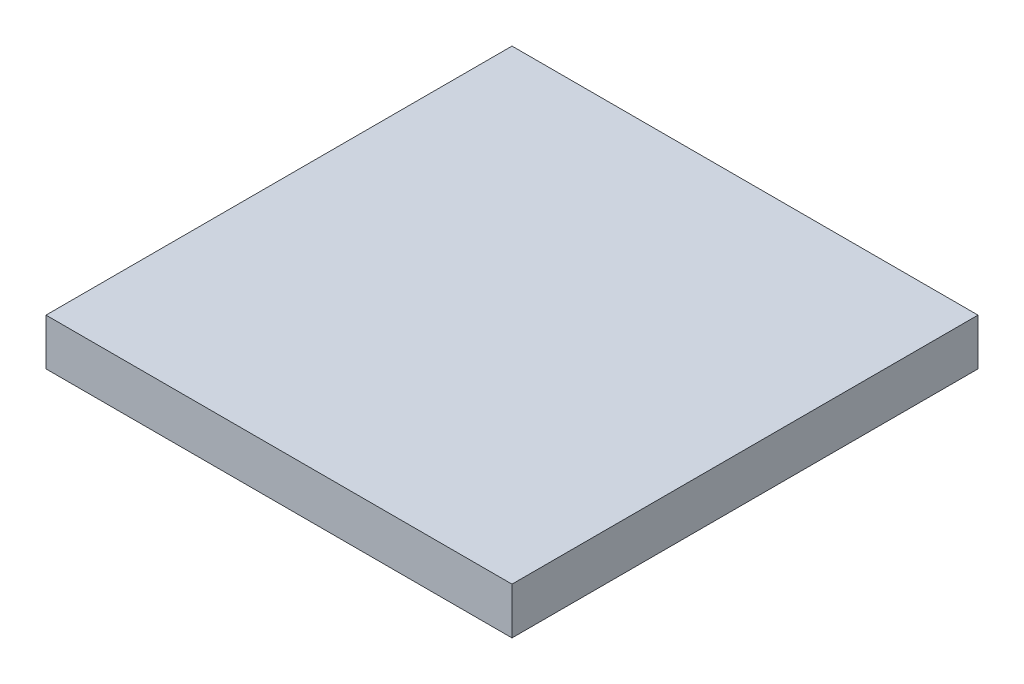
from build123d import *

# Parameters (mm, degrees)
SKETCH1_W           = 254
SKETCH1_H           = 254
BOSS_EXTRUDE2_DEPTH = 25.4
SKETCH3_W           = 228.6
SKETCH3_H           = 0.8128
CUT_EXTRUDE1_DEPTH  = 5.08


with BuildPart() as part:
    # Sketch1 → Boss-Extrude2 (new body)
    with BuildSketch(Plane(origin=(0, 0, 0), x_dir=(1, 0, 0), z_dir=(0, 1, 0))):
        Rectangle(SKETCH1_W, SKETCH1_H)
    extrude(amount=BOSS_EXTRUDE2_DEPTH)

    # Sketch3 → Cut-Extrude1 (cut)
    with BuildSketch(Plane(origin=(0, 0, 0), x_dir=(1, 0, 0), z_dir=(0, 1, 0))):
        with Locations((0, 89.3064)):
            Rectangle(SKETCH3_W, SKETCH3_H)
        with Locations((0, 63.9064)):
            Rectangle(SKETCH3_W, SKETCH3_H)
        with Locations((0, 38.5064)):
            Rectangle(SKETCH3_W, SKETCH3_H)
        with Locations((0, 13.1064)):
            Rectangle(SKETCH3_W, SKETCH3_H)
        with Locations((0, -13.1064)):
            Rectangle(SKETCH3_W, SKETCH3_H)
        with Locations((0, -38.5064)):
            Rectangle(SKETCH3_W, SKETCH3_H)
        with Locations((0, -63.9064)):
            Rectangle(SKETCH3_W, SKETCH3_H)
        with Locations((0, -89.3064)):
            Rectangle(SKETCH3_W, SKETCH3_H)
    extrude(amount=CUT_EXTRUDE1_DEPTH, mode=Mode.SUBTRACT)


solid = part.part
